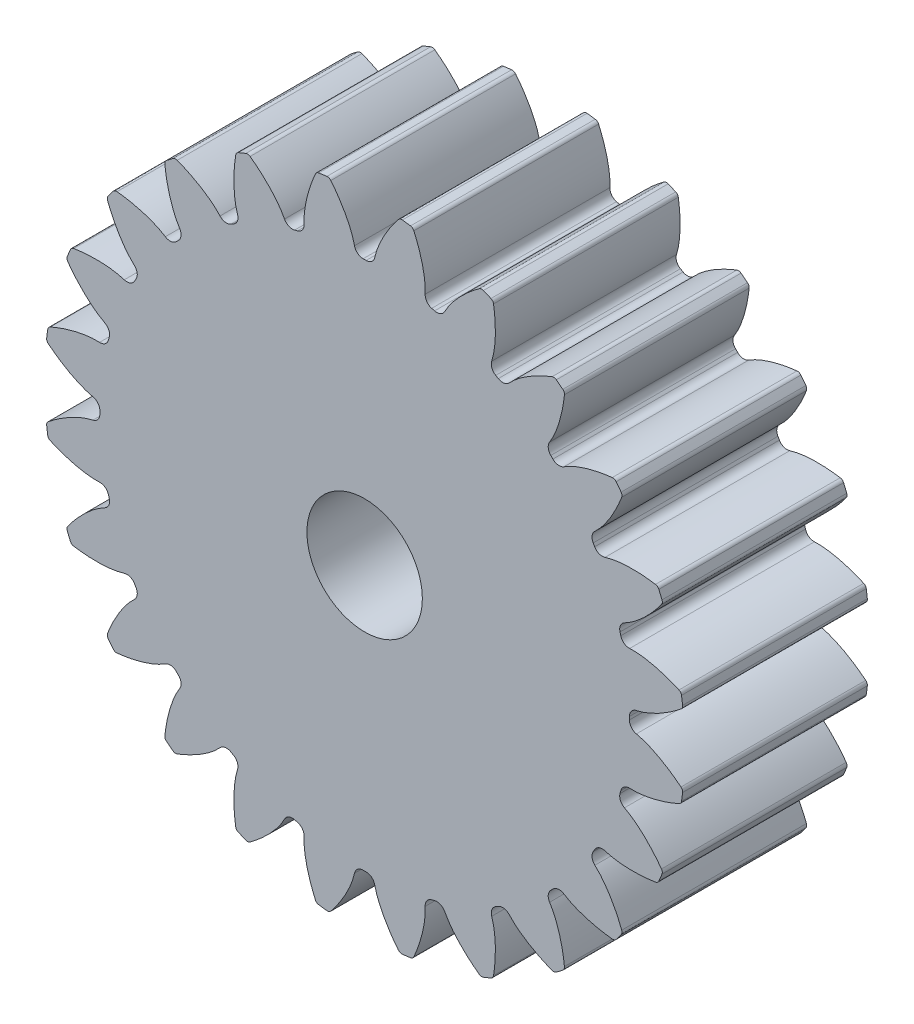
from build123d import *

# Parameters (mm, degrees)
SKETCH1_R                                 = 22.013333333
BOSS_EXTRUDE1_DEPTH                       = 12.7
CUT_EXTRUDE_DCLTBC_DEPTH                  = 13.7
FILLET_TIP_DCLTBC_R                       = 0.301120865
FILLET_ROOT_DCLTBC_R                      = 0.602241731
CIRPATTERN_DCLTBC_COUNT                   = 24
FILLET_TIP_DCLTBC_OF_CIRPATTERN_DCLTBC_R  = 0.301120865
FILLET_ROOT_DCLTBC_OF_CIRPATTERN_DCLTBC_R = 0.602241731
SKETCH8_R                                 = 3.96875
CUT_EXTRUDE5_DEPTH                        = 25.4


with BuildPart() as part:
    # Sketch1 → Boss-Extrude1 (new body)
    with BuildSketch(Plane.XY):
        Circle(SKETCH1_R)
    extrude(amount=BOSS_EXTRUDE1_DEPTH)

    # DCLTBC → Cut-Extrude-DCLTBC (cut, through all)
    with BuildSketch(Plane.XY):
        with BuildLine():
            Line((-0.65316759, 18.40458762), (-0.645618749, 18.191880631))
            ThreePointArc((-0.645618749, 18.191880631), (0, 18.203333333), (0.645618749, 18.191880631))
            Line((0.645618749, 18.191880631), (0.65316759, 18.40458762))
            add(Edge.make_bspline(
                [(0.65316759, 18.40458762), (0.653455488, 18.41041931), (0.654513176, 18.426763296), (0.657500609, 18.4576082), (0.663776304, 18.507831806), (0.673829279, 18.571642864), (0.68917972, 18.653865984), (0.710287754, 18.750357216), (0.736645624, 18.855957946), (0.76872217, 18.970315677), (0.803721487, 19.083890812), (0.841416112, 19.196668946), (0.881468461, 19.308519325), (0.932929894, 19.443377919), (0.998724669, 19.604184964), (1.081547695, 19.790715524), (1.182440671, 20.000496086), (1.292649071, 20.212244804), (1.407142048, 20.418866576), (1.529709249, 20.625480648), (1.653176589, 20.823856906), (1.788390425, 21.02752824), (1.916752528, 21.214328562), (2.068189061, 21.420811695), (2.192634463, 21.58664135), (2.327481485, 21.755498466), (2.394038027, 21.837316444), (2.428441227, 21.878974328)],
                knots=[0, 0, 0, 0, 0, 0.005376749, 0.015083688, 0.02853182, 0.04661014, 0.064854849, 0.092110526, 0.119476176, 0.146842496, 0.174208854, 0.201574956, 0.228941013, 0.256307345, 0.307035032, 0.361767352, 0.416499661, 0.471231937, 0.525964282, 0.580696616, 0.635428982, 0.690161387, 0.744893688, 0.799626082, 0.854358408, 0.909090915, 0.909090915, 0.909090915, 0.909090915, 0.909090915], degree=4))
            ThreePointArc((2.428441227, 21.878974328), (0, 22.013333333), (-2.428441227, 21.878974328))
            add(Edge.make_bspline(
                [(-0.65316759, 18.40458762), (-0.653455488, 18.41041931), (-0.654513176, 18.426763296), (-0.657500609, 18.4576082), (-0.663776304, 18.507831806), (-0.673829279, 18.571642864), (-0.68917972, 18.653865984), (-0.710287754, 18.750357216), (-0.736645624, 18.855957946), (-0.76872217, 18.970315677), (-0.803721487, 19.083890812), (-0.841416112, 19.196668946), (-0.881468461, 19.308519325), (-0.932929894, 19.443377919), (-0.998724669, 19.604184964), (-1.081547695, 19.790715524), (-1.182440671, 20.000496086), (-1.292649071, 20.212244804), (-1.407142048, 20.418866576), (-1.529709249, 20.625480648), (-1.653176589, 20.823856906), (-1.788390425, 21.02752824), (-1.916752528, 21.214328562), (-2.068189061, 21.420811695), (-2.192634463, 21.58664135), (-2.327481485, 21.755498466), (-2.394038027, 21.837316444), (-2.428441227, 21.878974328)],
                knots=[0, 0, 0, 0, 0, 0.005376749, 0.015083688, 0.02853182, 0.04661014, 0.064854849, 0.092110526, 0.119476176, 0.146842496, 0.174208854, 0.201574956, 0.228941013, 0.256307345, 0.307035032, 0.361767352, 0.416499661, 0.471231937, 0.525964282, 0.580696616, 0.635428982, 0.690161387, 0.744893688, 0.799626082, 0.854358408, 0.909090915, 0.909090915, 0.909090915, 0.909090915, 0.909090915], degree=4))
        make_face()
    cut_extrude_dcltbc = extrude(amount=CUT_EXTRUDE_DCLTBC_DEPTH, mode=Mode.SUBTRACT)

    # Fillet-Tip-DCLTBC
    fillet_tip_dcltbc_edges = [part.edges().sort_by_distance(p)[0] for p in [
        (2.428441227, 21.878974328, 6.35),
        (-2.428441227, 21.878974328, 6.35),
    ]]
    fillet(fillet_tip_dcltbc_edges, radius=FILLET_TIP_DCLTBC_R)

    # Fillet-Root-DCLTBC
    fillet_root_dcltbc_edges = [part.edges().sort_by_distance(p)[0] for p in [
        (-0.645618749, 18.191880631, 6.35),
        (0.645618749, 18.191880631, 6.35),
    ]]
    fillet(fillet_root_dcltbc_edges, radius=FILLET_ROOT_DCLTBC_R)

    # CirPattern-DCLTBC: Cut-Extrude-DCLTBC ×24 about axis
    cirpattern_dcltbc_axis = Axis((0, 0, 12.7), (0, 0, 1))
    for i in range(1, CIRPATTERN_DCLTBC_COUNT):
        add(cut_extrude_dcltbc.rotate(cirpattern_dcltbc_axis, i * 360 / CIRPATTERN_DCLTBC_COUNT), mode=Mode.SUBTRACT)

    # Fillet-Tip-DCLTBC of CirPattern-DCLTBC
    fillet_tip_dcltbc_of_cirpattern_dcltbc_edges = [part.edges().sort_by_distance(p)[0] for p in [
        (-3.317001145, 21.761993196, 6.35),
        (-8.008389342, 20.504939517, 6.35),
        (-8.83639537, 20.16196819, 6.35),
        (-13.042578958, 17.733526963, 6.35),
        (-13.753603853, 17.187938372, 6.35),
        (-17.187938372, 13.753603853, 6.35),
        (-17.733526963, 13.042578958, 6.35),
        (-20.16196819, 8.83639537, 6.35),
        (-20.504939517, 8.008389342, 6.35),
        (-21.761993196, 3.317001145, 6.35),
        (-21.878974328, 2.428441227, 6.35),
        (-21.878974328, -2.428441227, 6.35),
        (-21.761993196, -3.317001145, 6.35),
        (-20.504939517, -8.008389342, 6.35),
        (-20.16196819, -8.83639537, 6.35),
        (-17.733526963, -13.042578958, 6.35),
        (-17.187938372, -13.753603853, 6.35),
        (-13.753603853, -17.187938372, 6.35),
        (-13.042578958, -17.733526963, 6.35),
        (-8.83639537, -20.16196819, 6.35),
        (-8.008389342, -20.504939517, 6.35),
        (-3.317001145, -21.761993196, 6.35),
        (-2.428441227, -21.878974328, 6.35),
        (2.428441227, -21.878974328, 6.35),
        (3.317001145, -21.761993196, 6.35),
        (8.008389342, -20.504939517, 6.35),
        (8.83639537, -20.16196819, 6.35),
        (13.042578958, -17.733526963, 6.35),
        (13.753603853, -17.187938372, 6.35),
        (17.187938372, -13.753603853, 6.35),
        (17.733526963, -13.042578958, 6.35),
        (20.16196819, -8.83639537, 6.35),
        (20.504939517, -8.008389342, 6.35),
        (21.761993196, -3.317001145, 6.35),
        (21.878974328, -2.428441227, 6.35),
        (21.878974328, 2.428441227, 6.35),
        (21.761993196, 3.317001145, 6.35),
        (20.504939517, 8.008389342, 6.35),
        (20.16196819, 8.83639537, 6.35),
        (17.733526963, 13.042578958, 6.35),
        (17.187938372, 13.753603853, 6.35),
        (13.753603853, 17.187938372, 6.35),
        (13.042578958, 17.733526963, 6.35),
        (8.83639537, 20.16196819, 6.35),
        (8.008389342, 20.504939517, 6.35),
        (3.317001145, 21.761993196, 6.35),
    ]]
    fillet(fillet_tip_dcltbc_of_cirpattern_dcltbc_edges, radius=FILLET_TIP_DCLTBC_OF_CIRPATTERN_DCLTBC_R)

    # Fillet-Root-DCLTBC of CirPattern-DCLTBC
    fillet_root_dcltbc_of_cirpattern_dcltbc_edges = [part.edges().sort_by_distance(p)[0] for p in [
        (-5.332024997, 17.404908902, 6.35),
        (-4.08478535, 17.739105758, 6.35),
        (-9.655062553, 15.431821394, 6.35),
        (-8.536818077, 16.077440143, 6.35),
        (-13.320123552, 12.407080761, 6.35),
        (-12.407080761, 13.320123552, 6.35),
        (-16.077440143, 8.536818077, 6.35),
        (-15.431821394, 9.655062553, 6.35),
        (-17.739105758, 4.08478535, 6.35),
        (-17.404908902, 5.332024997, 6.35),
        (-18.191880631, -0.645618749, 6.35),
        (-18.191880631, 0.645618749, 6.35),
        (-17.404908902, -5.332024997, 6.35),
        (-17.739105758, -4.08478535, 6.35),
        (-15.431821394, -9.655062553, 6.35),
        (-16.077440143, -8.536818077, 6.35),
        (-12.407080761, -13.320123552, 6.35),
        (-13.320123552, -12.407080761, 6.35),
        (-8.536818077, -16.077440143, 6.35),
        (-9.655062553, -15.431821394, 6.35),
        (-4.08478535, -17.739105758, 6.35),
        (-5.332024997, -17.404908902, 6.35),
        (0.645618749, -18.191880631, 6.35),
        (-0.645618749, -18.191880631, 6.35),
        (5.332024997, -17.404908902, 6.35),
        (4.08478535, -17.739105758, 6.35),
        (9.655062553, -15.431821394, 6.35),
        (8.536818077, -16.077440143, 6.35),
        (13.320123552, -12.407080761, 6.35),
        (12.407080761, -13.320123552, 6.35),
        (16.077440143, -8.536818077, 6.35),
        (15.431821394, -9.655062553, 6.35),
        (17.739105758, -4.08478535, 6.35),
        (17.404908902, -5.332024997, 6.35),
        (18.191880631, 0.645618749, 6.35),
        (18.191880631, -0.645618749, 6.35),
        (17.404908902, 5.332024997, 6.35),
        (17.739105758, 4.08478535, 6.35),
        (15.431821394, 9.655062553, 6.35),
        (16.077440143, 8.536818077, 6.35),
        (12.407080761, 13.320123552, 6.35),
        (13.320123552, 12.407080761, 6.35),
        (8.536818077, 16.077440143, 6.35),
        (9.655062553, 15.431821394, 6.35),
        (4.08478535, 17.739105758, 6.35),
        (5.332024997, 17.404908902, 6.35),
    ]]
    fillet(fillet_root_dcltbc_of_cirpattern_dcltbc_edges, radius=FILLET_ROOT_DCLTBC_OF_CIRPATTERN_DCLTBC_R)

    # Sketch8 → Cut-Extrude5 (cut)
    with BuildSketch(Plane.XY):
        Circle(SKETCH8_R)
    extrude(amount=CUT_EXTRUDE5_DEPTH, mode=Mode.SUBTRACT)


solid = part.part
